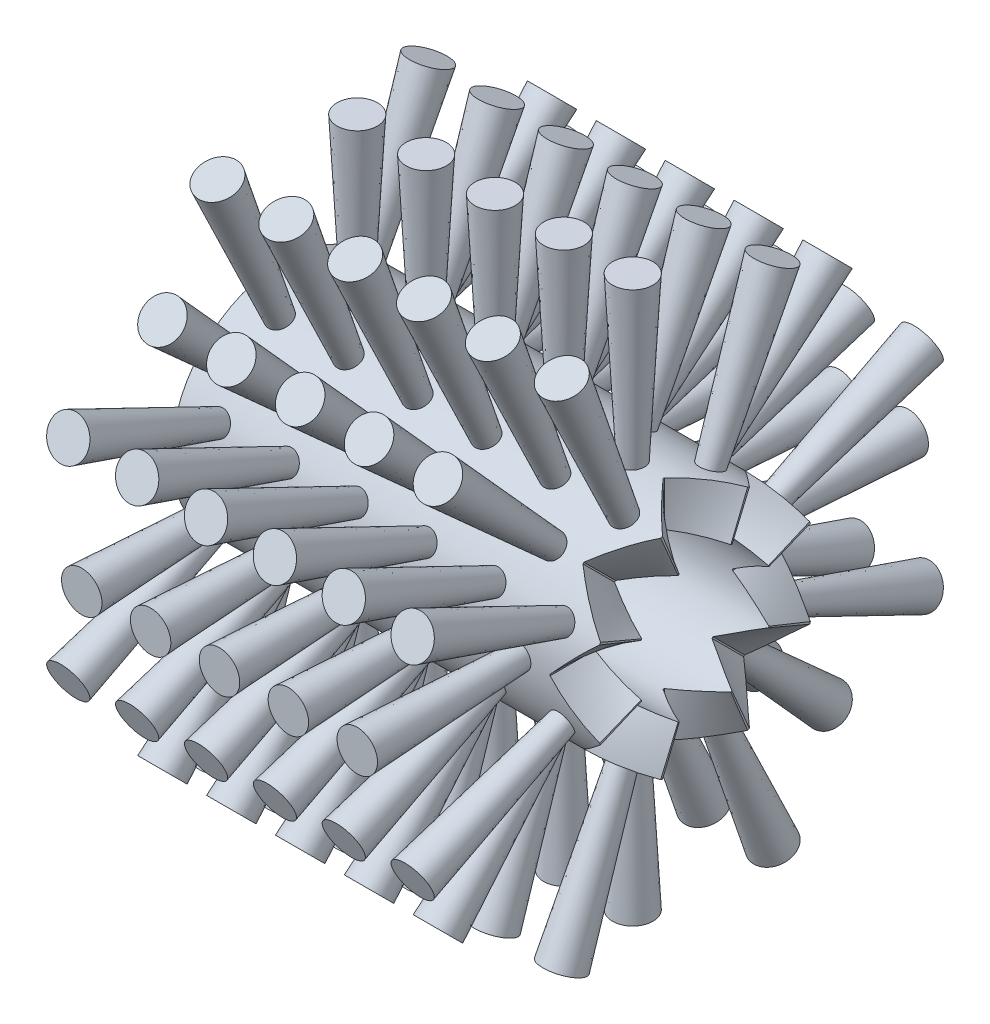
from build123d import *

# Parameters (mm, degrees)
SKIZZE1_R                         = 16.5
SKIZZE1_R_2                       = 10
LINEAR_AUSTRAGEN1_DEPTH           = 61
KREISMUSTER1_COUNT                = 8
SKIZZE8_R                         = 1.6
B_RSTE1_DEPTH                     = 25.5
B_RSTE1_TAPER                     = -3
SKIZZE9_R                         = 1.6
B_RTSE2_DEPTH                     = 25.5
B_RTSE2_TAPER                     = -3
KREISMUSTER3_COUNT                = 8
LINEARES_MUSTER1_COUNT            = 5
LINEARES_MUSTER1_PITCH            = 10
LINEARES_MUSTER1_COPY_1_SKETCH_R  = 1.6
LINEARES_MUSTER1_COPY_1_DEPTH     = 25.5
LINEARES_MUSTER1_COPY_1_TAPER     = -3
LINEARES_MUSTER1_COPY_2_SKETCH_R  = 1.6
LINEARES_MUSTER1_COPY_2_DEPTH     = 25.5
LINEARES_MUSTER1_COPY_2_TAPER     = -3
LINEARES_MUSTER1_COPY_3_SKETCH_R  = 1.6
LINEARES_MUSTER1_COPY_3_DEPTH     = 25.5
LINEARES_MUSTER1_COPY_3_TAPER     = -3
LINEARES_MUSTER1_COPY_4_SKETCH_R  = 1.6
LINEARES_MUSTER1_COPY_4_DEPTH     = 25.5
LINEARES_MUSTER1_COPY_4_TAPER     = -3
LINEARES_MUSTER1_COPY_5_SKETCH_R  = 1.6
LINEARES_MUSTER1_COPY_5_DEPTH     = 25.5
LINEARES_MUSTER1_COPY_5_TAPER     = -3
LINEARES_MUSTER1_COPY_6_SKETCH_R  = 1.6
LINEARES_MUSTER1_COPY_6_DEPTH     = 25.5
LINEARES_MUSTER1_COPY_6_TAPER     = -3
LINEARES_MUSTER1_COPY_7_SKETCH_R  = 1.6
LINEARES_MUSTER1_COPY_7_DEPTH     = 25.5
LINEARES_MUSTER1_COPY_7_TAPER     = -3
LINEARES_MUSTER1_COPY_8_SKETCH_R  = 1.6
LINEARES_MUSTER1_COPY_8_DEPTH     = 25.5
LINEARES_MUSTER1_COPY_8_TAPER     = -3
LINEARES_MUSTER1_COPY_9_SKETCH_R  = 1.6
LINEARES_MUSTER1_COPY_9_DEPTH     = 25.5
LINEARES_MUSTER1_COPY_9_TAPER     = -3
LINEARES_MUSTER1_COPY_10_SKETCH_R = 1.6
LINEARES_MUSTER1_COPY_10_DEPTH    = 25.5
LINEARES_MUSTER1_COPY_10_TAPER    = -3
LINEARES_MUSTER1_COPY_11_SKETCH_R = 1.6
LINEARES_MUSTER1_COPY_11_DEPTH    = 25.5
LINEARES_MUSTER1_COPY_11_TAPER    = -3
LINEARES_MUSTER1_COPY_12_SKETCH_R = 1.6
LINEARES_MUSTER1_COPY_12_DEPTH    = 25.5
LINEARES_MUSTER1_COPY_12_TAPER    = -3
LINEARES_MUSTER1_COPY_13_SKETCH_R = 1.6
LINEARES_MUSTER1_COPY_13_DEPTH    = 25.5
LINEARES_MUSTER1_COPY_13_TAPER    = -3
LINEARES_MUSTER1_COPY_14_SKETCH_R = 1.6
LINEARES_MUSTER1_COPY_14_DEPTH    = 25.5
LINEARES_MUSTER1_COPY_14_TAPER    = -3
LINEARES_MUSTER1_COPY_15_SKETCH_R = 1.6
LINEARES_MUSTER1_COPY_15_DEPTH    = 25.5
LINEARES_MUSTER1_COPY_15_TAPER    = -3
LINEARES_MUSTER1_COPY_16_SKETCH_R = 1.6
LINEARES_MUSTER1_COPY_16_DEPTH    = 25.5
LINEARES_MUSTER1_COPY_16_TAPER    = -3
LINEARES_MUSTER1_COPY_17_SKETCH_R = 1.6
LINEARES_MUSTER1_COPY_17_DEPTH    = 25.5
LINEARES_MUSTER1_COPY_17_TAPER    = -3
LINEARES_MUSTER1_COPY_18_SKETCH_R = 1.6
LINEARES_MUSTER1_COPY_18_DEPTH    = 25.5
LINEARES_MUSTER1_COPY_18_TAPER    = -3
LINEARES_MUSTER1_COPY_19_SKETCH_R = 1.6
LINEARES_MUSTER1_COPY_19_DEPTH    = 25.5
LINEARES_MUSTER1_COPY_19_TAPER    = -3
LINEARES_MUSTER1_COPY_20_SKETCH_R = 1.6
LINEARES_MUSTER1_COPY_20_DEPTH    = 25.5
LINEARES_MUSTER1_COPY_20_TAPER    = -3
LINEARES_MUSTER1_COPY_21_SKETCH_R = 1.6
LINEARES_MUSTER1_COPY_21_DEPTH    = 25.5
LINEARES_MUSTER1_COPY_21_TAPER    = -3
LINEARES_MUSTER1_COPY_22_SKETCH_R = 1.6
LINEARES_MUSTER1_COPY_22_DEPTH    = 25.5
LINEARES_MUSTER1_COPY_22_TAPER    = -3
LINEARES_MUSTER1_COPY_23_SKETCH_R = 1.6
LINEARES_MUSTER1_COPY_23_DEPTH    = 25.5
LINEARES_MUSTER1_COPY_23_TAPER    = -3
LINEARES_MUSTER1_COPY_24_SKETCH_R = 1.6
LINEARES_MUSTER1_COPY_24_DEPTH    = 25.5
LINEARES_MUSTER1_COPY_24_TAPER    = -3
LINEARES_MUSTER1_COPY_25_SKETCH_R = 1.6
LINEARES_MUSTER1_COPY_25_DEPTH    = 25.5
LINEARES_MUSTER1_COPY_25_TAPER    = -3
LINEARES_MUSTER1_COPY_26_SKETCH_R = 1.6
LINEARES_MUSTER1_COPY_26_DEPTH    = 25.5
LINEARES_MUSTER1_COPY_26_TAPER    = -3
LINEARES_MUSTER1_COPY_27_SKETCH_R = 1.6
LINEARES_MUSTER1_COPY_27_DEPTH    = 25.5
LINEARES_MUSTER1_COPY_27_TAPER    = -3
LINEARES_MUSTER1_COPY_28_SKETCH_R = 1.6
LINEARES_MUSTER1_COPY_28_DEPTH    = 25.5
LINEARES_MUSTER1_COPY_28_TAPER    = -3
KREISMUSTER4_COUNT                = 8
LINEARES_MUSTER2_COUNT            = 6
LINEARES_MUSTER2_PITCH            = 10
LINEARES_MUSTER2_COPY_1_SKETCH_R  = 1.6
LINEARES_MUSTER2_COPY_1_DEPTH     = 25.5
LINEARES_MUSTER2_COPY_1_TAPER     = -3
LINEARES_MUSTER2_COPY_2_SKETCH_R  = 1.6
LINEARES_MUSTER2_COPY_2_DEPTH     = 25.5
LINEARES_MUSTER2_COPY_2_TAPER     = -3
LINEARES_MUSTER2_COPY_3_SKETCH_R  = 1.6
LINEARES_MUSTER2_COPY_3_DEPTH     = 25.5
LINEARES_MUSTER2_COPY_3_TAPER     = -3
LINEARES_MUSTER2_COPY_4_SKETCH_R  = 1.6
LINEARES_MUSTER2_COPY_4_DEPTH     = 25.5
LINEARES_MUSTER2_COPY_4_TAPER     = -3
LINEARES_MUSTER2_COPY_5_SKETCH_R  = 1.6
LINEARES_MUSTER2_COPY_5_DEPTH     = 25.5
LINEARES_MUSTER2_COPY_5_TAPER     = -3
LINEARES_MUSTER2_COPY_6_SKETCH_R  = 1.6
LINEARES_MUSTER2_COPY_6_DEPTH     = 25.5
LINEARES_MUSTER2_COPY_6_TAPER     = -3
LINEARES_MUSTER2_COPY_7_SKETCH_R  = 1.6
LINEARES_MUSTER2_COPY_7_DEPTH     = 25.5
LINEARES_MUSTER2_COPY_7_TAPER     = -3
LINEARES_MUSTER2_COPY_8_SKETCH_R  = 1.6
LINEARES_MUSTER2_COPY_8_DEPTH     = 25.5
LINEARES_MUSTER2_COPY_8_TAPER     = -3
LINEARES_MUSTER2_COPY_9_SKETCH_R  = 1.6
LINEARES_MUSTER2_COPY_9_DEPTH     = 25.5
LINEARES_MUSTER2_COPY_9_TAPER     = -3
LINEARES_MUSTER2_COPY_10_SKETCH_R = 1.6
LINEARES_MUSTER2_COPY_10_DEPTH    = 25.5
LINEARES_MUSTER2_COPY_10_TAPER    = -3
LINEARES_MUSTER2_COPY_11_SKETCH_R = 1.6
LINEARES_MUSTER2_COPY_11_DEPTH    = 25.5
LINEARES_MUSTER2_COPY_11_TAPER    = -3
LINEARES_MUSTER2_COPY_12_SKETCH_R = 1.6
LINEARES_MUSTER2_COPY_12_DEPTH    = 25.5
LINEARES_MUSTER2_COPY_12_TAPER    = -3
LINEARES_MUSTER2_COPY_13_SKETCH_R = 1.6
LINEARES_MUSTER2_COPY_13_DEPTH    = 25.5
LINEARES_MUSTER2_COPY_13_TAPER    = -3
LINEARES_MUSTER2_COPY_14_SKETCH_R = 1.6
LINEARES_MUSTER2_COPY_14_DEPTH    = 25.5
LINEARES_MUSTER2_COPY_14_TAPER    = -3
LINEARES_MUSTER2_COPY_15_SKETCH_R = 1.6
LINEARES_MUSTER2_COPY_15_DEPTH    = 25.5
LINEARES_MUSTER2_COPY_15_TAPER    = -3
LINEARES_MUSTER2_COPY_16_SKETCH_R = 1.6
LINEARES_MUSTER2_COPY_16_DEPTH    = 25.5
LINEARES_MUSTER2_COPY_16_TAPER    = -3
LINEARES_MUSTER2_COPY_17_SKETCH_R = 1.6
LINEARES_MUSTER2_COPY_17_DEPTH    = 25.5
LINEARES_MUSTER2_COPY_17_TAPER    = -3
LINEARES_MUSTER2_COPY_18_SKETCH_R = 1.6
LINEARES_MUSTER2_COPY_18_DEPTH    = 25.5
LINEARES_MUSTER2_COPY_18_TAPER    = -3
LINEARES_MUSTER2_COPY_19_SKETCH_R = 1.6
LINEARES_MUSTER2_COPY_19_DEPTH    = 25.5
LINEARES_MUSTER2_COPY_19_TAPER    = -3
LINEARES_MUSTER2_COPY_20_SKETCH_R = 1.6
LINEARES_MUSTER2_COPY_20_DEPTH    = 25.5
LINEARES_MUSTER2_COPY_20_TAPER    = -3
LINEARES_MUSTER2_COPY_21_SKETCH_R = 1.6
LINEARES_MUSTER2_COPY_21_DEPTH    = 25.5
LINEARES_MUSTER2_COPY_21_TAPER    = -3
LINEARES_MUSTER2_COPY_22_SKETCH_R = 1.6
LINEARES_MUSTER2_COPY_22_DEPTH    = 25.5
LINEARES_MUSTER2_COPY_22_TAPER    = -3
LINEARES_MUSTER2_COPY_23_SKETCH_R = 1.6
LINEARES_MUSTER2_COPY_23_DEPTH    = 25.5
LINEARES_MUSTER2_COPY_23_TAPER    = -3
LINEARES_MUSTER2_COPY_24_SKETCH_R = 1.6
LINEARES_MUSTER2_COPY_24_DEPTH    = 25.5
LINEARES_MUSTER2_COPY_24_TAPER    = -3
LINEARES_MUSTER2_COPY_25_SKETCH_R = 1.6
LINEARES_MUSTER2_COPY_25_DEPTH    = 25.5
LINEARES_MUSTER2_COPY_25_TAPER    = -3
LINEARES_MUSTER2_COPY_26_SKETCH_R = 1.6
LINEARES_MUSTER2_COPY_26_DEPTH    = 25.5
LINEARES_MUSTER2_COPY_26_TAPER    = -3
LINEARES_MUSTER2_COPY_27_SKETCH_R = 1.6
LINEARES_MUSTER2_COPY_27_DEPTH    = 25.5
LINEARES_MUSTER2_COPY_27_TAPER    = -3
LINEARES_MUSTER2_COPY_28_SKETCH_R = 1.6
LINEARES_MUSTER2_COPY_28_DEPTH    = 25.5
LINEARES_MUSTER2_COPY_28_TAPER    = -3
LINEARES_MUSTER2_COPY_29_SKETCH_R = 1.6
LINEARES_MUSTER2_COPY_29_DEPTH    = 25.5
LINEARES_MUSTER2_COPY_29_TAPER    = -3
LINEARES_MUSTER2_COPY_30_SKETCH_R = 1.6
LINEARES_MUSTER2_COPY_30_DEPTH    = 25.5
LINEARES_MUSTER2_COPY_30_TAPER    = -3
LINEARES_MUSTER2_COPY_31_SKETCH_R = 1.6
LINEARES_MUSTER2_COPY_31_DEPTH    = 25.5
LINEARES_MUSTER2_COPY_31_TAPER    = -3
LINEARES_MUSTER2_COPY_32_SKETCH_R = 1.6
LINEARES_MUSTER2_COPY_32_DEPTH    = 25.5
LINEARES_MUSTER2_COPY_32_TAPER    = -3
LINEARES_MUSTER2_COPY_33_SKETCH_R = 1.6
LINEARES_MUSTER2_COPY_33_DEPTH    = 25.5
LINEARES_MUSTER2_COPY_33_TAPER    = -3
LINEARES_MUSTER2_COPY_34_SKETCH_R = 1.6
LINEARES_MUSTER2_COPY_34_DEPTH    = 25.5
LINEARES_MUSTER2_COPY_34_TAPER    = -3
LINEARES_MUSTER2_COPY_35_SKETCH_R = 1.6
LINEARES_MUSTER2_COPY_35_DEPTH    = 25.5
LINEARES_MUSTER2_COPY_35_TAPER    = -3


with BuildPart() as part:
    # Skizze1 → Linear austragen1 (new body)
    with BuildSketch(Plane(origin=(0, 0, 0), x_dir=(0, 0, -1), z_dir=(1, 0, 0))):
        Circle(SKIZZE1_R)
        Circle(SKIZZE1_R_2, mode=Mode.SUBTRACT)
    extrude(amount=LINEAR_AUSTRAGEN1_DEPTH)

    # Skizze5 → Schnitt-Ausformung1 section 0
    with BuildSketch(Plane(origin=(0, 8, 0), x_dir=(-1, 0, 0), z_dir=(0, 1, 0))):
        Polygon((-61, 3.232209807), (-55, 0.1), (-55, -0.1), (-61, -3.232209807), align=None)
    # Skizze4 → Schnitt-Ausformung1 section 1
    with BuildSketch(Plane(origin=(30.5, 16.5, 0), x_dir=(0, 0, -1), z_dir=(0, 1, 0))):
        Polygon((6.666432726, -30.5), (0.1, -24.5), (-0.1, -24.5), (-6.666432726, -30.5), align=None)
    schnitt_ausformung1 = loft(mode=Mode.SUBTRACT)

    # Kreismuster1: Schnitt-Ausformung1 ×8 about axis
    kreismuster1_axis = Axis((61, 0, 0), (-1, 0, 0))
    for i in range(1, KREISMUSTER1_COUNT):
        add(schnitt_ausformung1.rotate(kreismuster1_axis, i * 360 / KREISMUSTER1_COUNT), mode=Mode.SUBTRACT)

    # Skizze8 → Bürste1 (add)
    with BuildSketch(Plane(origin=(0, 14.5, 0), x_dir=(-1, 0, 0), z_dir=(0, 1, 0))):
        with Locations((-50.5, 0)):
            Circle(SKIZZE8_R)
    b_rste1 = extrude(amount=B_RSTE1_DEPTH, taper=B_RSTE1_TAPER)

    # Skizze9 → Bürtse2 (add)
    with BuildSketch(Plane(origin=(0, 13.396253221, 5.548909769), x_dir=(-1, 0, 0), z_dir=(0, 0.923879533, 0.382683432))):
        with Locations((-55.5, 0)):
            Circle(SKIZZE9_R)
    b_rtse2 = extrude(amount=B_RTSE2_DEPTH, taper=B_RTSE2_TAPER)

    # Kreismuster3: Bürste1 ×8 about axis
    kreismuster3_axis = Axis((0, 0, 0), (1, 0, 0))
    for i in range(1, KREISMUSTER3_COUNT):
        add(b_rste1.rotate(kreismuster3_axis, i * 360 / KREISMUSTER3_COUNT))

    # Lineares Muster1: Bürste1 ×5
    with Locations(*[(-i * LINEARES_MUSTER1_PITCH, 0, 0) for i in range(1, LINEARES_MUSTER1_COUNT)]):
        add(b_rste1)

    # Lineares Muster1 copy 1 sketch → Lineares Muster1 copy 1 (add)
    with BuildSketch(Plane(origin=(-10, 10.253048327, 10.253048327), x_dir=(-1, 0, 0), z_dir=(0, 0.707106781, 0.707106781))):
        with Locations((-50.5, 0)):
            Circle(LINEARES_MUSTER1_COPY_1_SKETCH_R)
    extrude(amount=LINEARES_MUSTER1_COPY_1_DEPTH, taper=LINEARES_MUSTER1_COPY_1_TAPER)

    # Lineares Muster1 copy 2 sketch → Lineares Muster1 copy 2 (add)
    with BuildSketch(Plane(origin=(-20, 10.253048327, 10.253048327), x_dir=(-1, 0, 0), z_dir=(0, 0.707106781, 0.707106781))):
        with Locations((-50.5, 0)):
            Circle(LINEARES_MUSTER1_COPY_2_SKETCH_R)
    extrude(amount=LINEARES_MUSTER1_COPY_2_DEPTH, taper=LINEARES_MUSTER1_COPY_2_TAPER)

    # Lineares Muster1 copy 3 sketch → Lineares Muster1 copy 3 (add)
    with BuildSketch(Plane(origin=(-30, 10.253048327, 10.253048327), x_dir=(-1, 0, 0), z_dir=(0, 0.707106781, 0.707106781))):
        with Locations((-50.5, 0)):
            Circle(LINEARES_MUSTER1_COPY_3_SKETCH_R)
    extrude(amount=LINEARES_MUSTER1_COPY_3_DEPTH, taper=LINEARES_MUSTER1_COPY_3_TAPER)

    # Lineares Muster1 copy 4 sketch → Lineares Muster1 copy 4 (add)
    with BuildSketch(Plane(origin=(-40, 10.253048327, 10.253048327), x_dir=(-1, 0, 0), z_dir=(0, 0.707106781, 0.707106781))):
        with Locations((-50.5, 0)):
            Circle(LINEARES_MUSTER1_COPY_4_SKETCH_R)
    extrude(amount=LINEARES_MUSTER1_COPY_4_DEPTH, taper=LINEARES_MUSTER1_COPY_4_TAPER)

    # Lineares Muster1 copy 5 sketch → Lineares Muster1 copy 5 (add)
    with BuildSketch(Plane(origin=(-10, 0, 14.5), x_dir=(-1, 0, 0), z_dir=(0, 0, 1))):
        with Locations((-50.5, 0)):
            Circle(LINEARES_MUSTER1_COPY_5_SKETCH_R)
    extrude(amount=LINEARES_MUSTER1_COPY_5_DEPTH, taper=LINEARES_MUSTER1_COPY_5_TAPER)

    # Lineares Muster1 copy 6 sketch → Lineares Muster1 copy 6 (add)
    with BuildSketch(Plane(origin=(-20, 0, 14.5), x_dir=(-1, 0, 0), z_dir=(0, 0, 1))):
        with Locations((-50.5, 0)):
            Circle(LINEARES_MUSTER1_COPY_6_SKETCH_R)
    extrude(amount=LINEARES_MUSTER1_COPY_6_DEPTH, taper=LINEARES_MUSTER1_COPY_6_TAPER)

    # Lineares Muster1 copy 7 sketch → Lineares Muster1 copy 7 (add)
    with BuildSketch(Plane(origin=(-30, 0, 14.5), x_dir=(-1, 0, 0), z_dir=(0, 0, 1))):
        with Locations((-50.5, 0)):
            Circle(LINEARES_MUSTER1_COPY_7_SKETCH_R)
    extrude(amount=LINEARES_MUSTER1_COPY_7_DEPTH, taper=LINEARES_MUSTER1_COPY_7_TAPER)

    # Lineares Muster1 copy 8 sketch → Lineares Muster1 copy 8 (add)
    with BuildSketch(Plane(origin=(-40, 0, 14.5), x_dir=(-1, 0, 0), z_dir=(0, 0, 1))):
        with Locations((-50.5, 0)):
            Circle(LINEARES_MUSTER1_COPY_8_SKETCH_R)
    extrude(amount=LINEARES_MUSTER1_COPY_8_DEPTH, taper=LINEARES_MUSTER1_COPY_8_TAPER)

    # Lineares Muster1 copy 9 sketch → Lineares Muster1 copy 9 (add)
    with BuildSketch(Plane(origin=(-10, -10.253048327, 10.253048327), x_dir=(-1, 0, 0), z_dir=(0, -0.707106781, 0.707106781))):
        with Locations((-50.5, 0)):
            Circle(LINEARES_MUSTER1_COPY_9_SKETCH_R)
    extrude(amount=LINEARES_MUSTER1_COPY_9_DEPTH, taper=LINEARES_MUSTER1_COPY_9_TAPER)

    # Lineares Muster1 copy 10 sketch → Lineares Muster1 copy 10 (add)
    with BuildSketch(Plane(origin=(-20, -10.253048327, 10.253048327), x_dir=(-1, 0, 0), z_dir=(0, -0.707106781, 0.707106781))):
        with Locations((-50.5, 0)):
            Circle(LINEARES_MUSTER1_COPY_10_SKETCH_R)
    extrude(amount=LINEARES_MUSTER1_COPY_10_DEPTH, taper=LINEARES_MUSTER1_COPY_10_TAPER)

    # Lineares Muster1 copy 11 sketch → Lineares Muster1 copy 11 (add)
    with BuildSketch(Plane(origin=(-30, -10.253048327, 10.253048327), x_dir=(-1, 0, 0), z_dir=(0, -0.707106781, 0.707106781))):
        with Locations((-50.5, 0)):
            Circle(LINEARES_MUSTER1_COPY_11_SKETCH_R)
    extrude(amount=LINEARES_MUSTER1_COPY_11_DEPTH, taper=LINEARES_MUSTER1_COPY_11_TAPER)

    # Lineares Muster1 copy 12 sketch → Lineares Muster1 copy 12 (add)
    with BuildSketch(Plane(origin=(-40, -10.253048327, 10.253048327), x_dir=(-1, 0, 0), z_dir=(0, -0.707106781, 0.707106781))):
        with Locations((-50.5, 0)):
            Circle(LINEARES_MUSTER1_COPY_12_SKETCH_R)
    extrude(amount=LINEARES_MUSTER1_COPY_12_DEPTH, taper=LINEARES_MUSTER1_COPY_12_TAPER)

    # Lineares Muster1 copy 13 sketch → Lineares Muster1 copy 13 (add)
    with BuildSketch(Plane(origin=(-10, -14.5, 0), x_dir=(-1, 0, 0), z_dir=(0, -1, 0))):
        with Locations((-50.5, 0)):
            Circle(LINEARES_MUSTER1_COPY_13_SKETCH_R)
    extrude(amount=LINEARES_MUSTER1_COPY_13_DEPTH, taper=LINEARES_MUSTER1_COPY_13_TAPER)

    # Lineares Muster1 copy 14 sketch → Lineares Muster1 copy 14 (add)
    with BuildSketch(Plane(origin=(-20, -14.5, 0), x_dir=(-1, 0, 0), z_dir=(0, -1, 0))):
        with Locations((-50.5, 0)):
            Circle(LINEARES_MUSTER1_COPY_14_SKETCH_R)
    extrude(amount=LINEARES_MUSTER1_COPY_14_DEPTH, taper=LINEARES_MUSTER1_COPY_14_TAPER)

    # Lineares Muster1 copy 15 sketch → Lineares Muster1 copy 15 (add)
    with BuildSketch(Plane(origin=(-30, -14.5, 0), x_dir=(-1, 0, 0), z_dir=(0, -1, 0))):
        with Locations((-50.5, 0)):
            Circle(LINEARES_MUSTER1_COPY_15_SKETCH_R)
    extrude(amount=LINEARES_MUSTER1_COPY_15_DEPTH, taper=LINEARES_MUSTER1_COPY_15_TAPER)

    # Lineares Muster1 copy 16 sketch → Lineares Muster1 copy 16 (add)
    with BuildSketch(Plane(origin=(-40, -14.5, 0), x_dir=(-1, 0, 0), z_dir=(0, -1, 0))):
        with Locations((-50.5, 0)):
            Circle(LINEARES_MUSTER1_COPY_16_SKETCH_R)
    extrude(amount=LINEARES_MUSTER1_COPY_16_DEPTH, taper=LINEARES_MUSTER1_COPY_16_TAPER)

    # Lineares Muster1 copy 17 sketch → Lineares Muster1 copy 17 (add)
    with BuildSketch(Plane(origin=(-10, -10.253048327, -10.253048327), x_dir=(-1, 0, 0), z_dir=(0, -0.707106781, -0.707106781))):
        with Locations((-50.5, 0)):
            Circle(LINEARES_MUSTER1_COPY_17_SKETCH_R)
    extrude(amount=LINEARES_MUSTER1_COPY_17_DEPTH, taper=LINEARES_MUSTER1_COPY_17_TAPER)

    # Lineares Muster1 copy 18 sketch → Lineares Muster1 copy 18 (add)
    with BuildSketch(Plane(origin=(-20, -10.253048327, -10.253048327), x_dir=(-1, 0, 0), z_dir=(0, -0.707106781, -0.707106781))):
        with Locations((-50.5, 0)):
            Circle(LINEARES_MUSTER1_COPY_18_SKETCH_R)
    extrude(amount=LINEARES_MUSTER1_COPY_18_DEPTH, taper=LINEARES_MUSTER1_COPY_18_TAPER)

    # Lineares Muster1 copy 19 sketch → Lineares Muster1 copy 19 (add)
    with BuildSketch(Plane(origin=(-30, -10.253048327, -10.253048327), x_dir=(-1, 0, 0), z_dir=(0, -0.707106781, -0.707106781))):
        with Locations((-50.5, 0)):
            Circle(LINEARES_MUSTER1_COPY_19_SKETCH_R)
    extrude(amount=LINEARES_MUSTER1_COPY_19_DEPTH, taper=LINEARES_MUSTER1_COPY_19_TAPER)

    # Lineares Muster1 copy 20 sketch → Lineares Muster1 copy 20 (add)
    with BuildSketch(Plane(origin=(-40, -10.253048327, -10.253048327), x_dir=(-1, 0, 0), z_dir=(0, -0.707106781, -0.707106781))):
        with Locations((-50.5, 0)):
            Circle(LINEARES_MUSTER1_COPY_20_SKETCH_R)
    extrude(amount=LINEARES_MUSTER1_COPY_20_DEPTH, taper=LINEARES_MUSTER1_COPY_20_TAPER)

    # Lineares Muster1 copy 21 sketch → Lineares Muster1 copy 21 (add)
    with BuildSketch(Plane(origin=(-10, 0, -14.5), x_dir=(-1, 0, 0), z_dir=(0, 0, -1))):
        with Locations((-50.5, 0)):
            Circle(LINEARES_MUSTER1_COPY_21_SKETCH_R)
    extrude(amount=LINEARES_MUSTER1_COPY_21_DEPTH, taper=LINEARES_MUSTER1_COPY_21_TAPER)

    # Lineares Muster1 copy 22 sketch → Lineares Muster1 copy 22 (add)
    with BuildSketch(Plane(origin=(-20, 0, -14.5), x_dir=(-1, 0, 0), z_dir=(0, 0, -1))):
        with Locations((-50.5, 0)):
            Circle(LINEARES_MUSTER1_COPY_22_SKETCH_R)
    extrude(amount=LINEARES_MUSTER1_COPY_22_DEPTH, taper=LINEARES_MUSTER1_COPY_22_TAPER)

    # Lineares Muster1 copy 23 sketch → Lineares Muster1 copy 23 (add)
    with BuildSketch(Plane(origin=(-30, 0, -14.5), x_dir=(-1, 0, 0), z_dir=(0, 0, -1))):
        with Locations((-50.5, 0)):
            Circle(LINEARES_MUSTER1_COPY_23_SKETCH_R)
    extrude(amount=LINEARES_MUSTER1_COPY_23_DEPTH, taper=LINEARES_MUSTER1_COPY_23_TAPER)

    # Lineares Muster1 copy 24 sketch → Lineares Muster1 copy 24 (add)
    with BuildSketch(Plane(origin=(-40, 0, -14.5), x_dir=(-1, 0, 0), z_dir=(0, 0, -1))):
        with Locations((-50.5, 0)):
            Circle(LINEARES_MUSTER1_COPY_24_SKETCH_R)
    extrude(amount=LINEARES_MUSTER1_COPY_24_DEPTH, taper=LINEARES_MUSTER1_COPY_24_TAPER)

    # Lineares Muster1 copy 25 sketch → Lineares Muster1 copy 25 (add)
    with BuildSketch(Plane(origin=(-10, 10.253048327, -10.253048327), x_dir=(-1, 0, 0), z_dir=(0, 0.707106781, -0.707106781))):
        with Locations((-50.5, 0)):
            Circle(LINEARES_MUSTER1_COPY_25_SKETCH_R)
    extrude(amount=LINEARES_MUSTER1_COPY_25_DEPTH, taper=LINEARES_MUSTER1_COPY_25_TAPER)

    # Lineares Muster1 copy 26 sketch → Lineares Muster1 copy 26 (add)
    with BuildSketch(Plane(origin=(-20, 10.253048327, -10.253048327), x_dir=(-1, 0, 0), z_dir=(0, 0.707106781, -0.707106781))):
        with Locations((-50.5, 0)):
            Circle(LINEARES_MUSTER1_COPY_26_SKETCH_R)
    extrude(amount=LINEARES_MUSTER1_COPY_26_DEPTH, taper=LINEARES_MUSTER1_COPY_26_TAPER)

    # Lineares Muster1 copy 27 sketch → Lineares Muster1 copy 27 (add)
    with BuildSketch(Plane(origin=(-30, 10.253048327, -10.253048327), x_dir=(-1, 0, 0), z_dir=(0, 0.707106781, -0.707106781))):
        with Locations((-50.5, 0)):
            Circle(LINEARES_MUSTER1_COPY_27_SKETCH_R)
    extrude(amount=LINEARES_MUSTER1_COPY_27_DEPTH, taper=LINEARES_MUSTER1_COPY_27_TAPER)

    # Lineares Muster1 copy 28 sketch → Lineares Muster1 copy 28 (add)
    with BuildSketch(Plane(origin=(-40, 10.253048327, -10.253048327), x_dir=(-1, 0, 0), z_dir=(0, 0.707106781, -0.707106781))):
        with Locations((-50.5, 0)):
            Circle(LINEARES_MUSTER1_COPY_28_SKETCH_R)
    extrude(amount=LINEARES_MUSTER1_COPY_28_DEPTH, taper=LINEARES_MUSTER1_COPY_28_TAPER)

    # Kreismuster4: Bürtse2 ×8 about axis
    kreismuster4_axis = Axis((0, 0, 0), (1, 0, 0))
    for i in range(1, KREISMUSTER4_COUNT):
        add(b_rtse2.rotate(kreismuster4_axis, i * 360 / KREISMUSTER4_COUNT))

    # Lineares Muster2: Bürtse2 ×6
    with Locations(*[(-i * LINEARES_MUSTER2_PITCH, 0, 0) for i in range(1, LINEARES_MUSTER2_COUNT)]):
        add(b_rtse2)

    # Lineares Muster2 copy 1 sketch → Lineares Muster2 copy 1 (add)
    with BuildSketch(Plane(origin=(-10, 5.548909769, 13.396253221), x_dir=(-1, 0, 0), z_dir=(0, 0.382683432, 0.923879533))):
        with Locations((-55.5, 0)):
            Circle(LINEARES_MUSTER2_COPY_1_SKETCH_R)
    extrude(amount=LINEARES_MUSTER2_COPY_1_DEPTH, taper=LINEARES_MUSTER2_COPY_1_TAPER)

    # Lineares Muster2 copy 2 sketch → Lineares Muster2 copy 2 (add)
    with BuildSketch(Plane(origin=(-20, 5.548909769, 13.396253221), x_dir=(-1, 0, 0), z_dir=(0, 0.382683432, 0.923879533))):
        with Locations((-55.5, 0)):
            Circle(LINEARES_MUSTER2_COPY_2_SKETCH_R)
    extrude(amount=LINEARES_MUSTER2_COPY_2_DEPTH, taper=LINEARES_MUSTER2_COPY_2_TAPER)

    # Lineares Muster2 copy 3 sketch → Lineares Muster2 copy 3 (add)
    with BuildSketch(Plane(origin=(-30, 5.548909769, 13.396253221), x_dir=(-1, 0, 0), z_dir=(0, 0.382683432, 0.923879533))):
        with Locations((-55.5, 0)):
            Circle(LINEARES_MUSTER2_COPY_3_SKETCH_R)
    extrude(amount=LINEARES_MUSTER2_COPY_3_DEPTH, taper=LINEARES_MUSTER2_COPY_3_TAPER)

    # Lineares Muster2 copy 4 sketch → Lineares Muster2 copy 4 (add)
    with BuildSketch(Plane(origin=(-40, 5.548909769, 13.396253221), x_dir=(-1, 0, 0), z_dir=(0, 0.382683432, 0.923879533))):
        with Locations((-55.5, 0)):
            Circle(LINEARES_MUSTER2_COPY_4_SKETCH_R)
    extrude(amount=LINEARES_MUSTER2_COPY_4_DEPTH, taper=LINEARES_MUSTER2_COPY_4_TAPER)

    # Lineares Muster2 copy 5 sketch → Lineares Muster2 copy 5 (add)
    with BuildSketch(Plane(origin=(-50, 5.548909769, 13.396253221), x_dir=(-1, 0, 0), z_dir=(0, 0.382683432, 0.923879533))):
        with Locations((-55.5, 0)):
            Circle(LINEARES_MUSTER2_COPY_5_SKETCH_R)
    extrude(amount=LINEARES_MUSTER2_COPY_5_DEPTH, taper=LINEARES_MUSTER2_COPY_5_TAPER)

    # Lineares Muster2 copy 6 sketch → Lineares Muster2 copy 6 (add)
    with BuildSketch(Plane(origin=(-10, -5.548909769, 13.396253221), x_dir=(-1, 0, 0), z_dir=(0, -0.382683432, 0.923879533))):
        with Locations((-55.5, 0)):
            Circle(LINEARES_MUSTER2_COPY_6_SKETCH_R)
    extrude(amount=LINEARES_MUSTER2_COPY_6_DEPTH, taper=LINEARES_MUSTER2_COPY_6_TAPER)

    # Lineares Muster2 copy 7 sketch → Lineares Muster2 copy 7 (add)
    with BuildSketch(Plane(origin=(-20, -5.548909769, 13.396253221), x_dir=(-1, 0, 0), z_dir=(0, -0.382683432, 0.923879533))):
        with Locations((-55.5, 0)):
            Circle(LINEARES_MUSTER2_COPY_7_SKETCH_R)
    extrude(amount=LINEARES_MUSTER2_COPY_7_DEPTH, taper=LINEARES_MUSTER2_COPY_7_TAPER)

    # Lineares Muster2 copy 8 sketch → Lineares Muster2 copy 8 (add)
    with BuildSketch(Plane(origin=(-30, -5.548909769, 13.396253221), x_dir=(-1, 0, 0), z_dir=(0, -0.382683432, 0.923879533))):
        with Locations((-55.5, 0)):
            Circle(LINEARES_MUSTER2_COPY_8_SKETCH_R)
    extrude(amount=LINEARES_MUSTER2_COPY_8_DEPTH, taper=LINEARES_MUSTER2_COPY_8_TAPER)

    # Lineares Muster2 copy 9 sketch → Lineares Muster2 copy 9 (add)
    with BuildSketch(Plane(origin=(-40, -5.548909769, 13.396253221), x_dir=(-1, 0, 0), z_dir=(0, -0.382683432, 0.923879533))):
        with Locations((-55.5, 0)):
            Circle(LINEARES_MUSTER2_COPY_9_SKETCH_R)
    extrude(amount=LINEARES_MUSTER2_COPY_9_DEPTH, taper=LINEARES_MUSTER2_COPY_9_TAPER)

    # Lineares Muster2 copy 10 sketch → Lineares Muster2 copy 10 (add)
    with BuildSketch(Plane(origin=(-50, -5.548909769, 13.396253221), x_dir=(-1, 0, 0), z_dir=(0, -0.382683432, 0.923879533))):
        with Locations((-55.5, 0)):
            Circle(LINEARES_MUSTER2_COPY_10_SKETCH_R)
    extrude(amount=LINEARES_MUSTER2_COPY_10_DEPTH, taper=LINEARES_MUSTER2_COPY_10_TAPER)

    # Lineares Muster2 copy 11 sketch → Lineares Muster2 copy 11 (add)
    with BuildSketch(Plane(origin=(-10, -13.396253221, 5.548909769), x_dir=(-1, 0, 0), z_dir=(0, -0.923879533, 0.382683432))):
        with Locations((-55.5, 0)):
            Circle(LINEARES_MUSTER2_COPY_11_SKETCH_R)
    extrude(amount=LINEARES_MUSTER2_COPY_11_DEPTH, taper=LINEARES_MUSTER2_COPY_11_TAPER)

    # Lineares Muster2 copy 12 sketch → Lineares Muster2 copy 12 (add)
    with BuildSketch(Plane(origin=(-20, -13.396253221, 5.548909769), x_dir=(-1, 0, 0), z_dir=(0, -0.923879533, 0.382683432))):
        with Locations((-55.5, 0)):
            Circle(LINEARES_MUSTER2_COPY_12_SKETCH_R)
    extrude(amount=LINEARES_MUSTER2_COPY_12_DEPTH, taper=LINEARES_MUSTER2_COPY_12_TAPER)

    # Lineares Muster2 copy 13 sketch → Lineares Muster2 copy 13 (add)
    with BuildSketch(Plane(origin=(-30, -13.396253221, 5.548909769), x_dir=(-1, 0, 0), z_dir=(0, -0.923879533, 0.382683432))):
        with Locations((-55.5, 0)):
            Circle(LINEARES_MUSTER2_COPY_13_SKETCH_R)
    extrude(amount=LINEARES_MUSTER2_COPY_13_DEPTH, taper=LINEARES_MUSTER2_COPY_13_TAPER)

    # Lineares Muster2 copy 14 sketch → Lineares Muster2 copy 14 (add)
    with BuildSketch(Plane(origin=(-40, -13.396253221, 5.548909769), x_dir=(-1, 0, 0), z_dir=(0, -0.923879533, 0.382683432))):
        with Locations((-55.5, 0)):
            Circle(LINEARES_MUSTER2_COPY_14_SKETCH_R)
    extrude(amount=LINEARES_MUSTER2_COPY_14_DEPTH, taper=LINEARES_MUSTER2_COPY_14_TAPER)

    # Lineares Muster2 copy 15 sketch → Lineares Muster2 copy 15 (add)
    with BuildSketch(Plane(origin=(-50, -13.396253221, 5.548909769), x_dir=(-1, 0, 0), z_dir=(0, -0.923879533, 0.382683432))):
        with Locations((-55.5, 0)):
            Circle(LINEARES_MUSTER2_COPY_15_SKETCH_R)
    extrude(amount=LINEARES_MUSTER2_COPY_15_DEPTH, taper=LINEARES_MUSTER2_COPY_15_TAPER)

    # Lineares Muster2 copy 16 sketch → Lineares Muster2 copy 16 (add)
    with BuildSketch(Plane(origin=(-10, -13.396253221, -5.548909769), x_dir=(-1, 0, 0), z_dir=(0, -0.923879533, -0.382683432))):
        with Locations((-55.5, 0)):
            Circle(LINEARES_MUSTER2_COPY_16_SKETCH_R)
    extrude(amount=LINEARES_MUSTER2_COPY_16_DEPTH, taper=LINEARES_MUSTER2_COPY_16_TAPER)

    # Lineares Muster2 copy 17 sketch → Lineares Muster2 copy 17 (add)
    with BuildSketch(Plane(origin=(-20, -13.396253221, -5.548909769), x_dir=(-1, 0, 0), z_dir=(0, -0.923879533, -0.382683432))):
        with Locations((-55.5, 0)):
            Circle(LINEARES_MUSTER2_COPY_17_SKETCH_R)
    extrude(amount=LINEARES_MUSTER2_COPY_17_DEPTH, taper=LINEARES_MUSTER2_COPY_17_TAPER)

    # Lineares Muster2 copy 18 sketch → Lineares Muster2 copy 18 (add)
    with BuildSketch(Plane(origin=(-30, -13.396253221, -5.548909769), x_dir=(-1, 0, 0), z_dir=(0, -0.923879533, -0.382683432))):
        with Locations((-55.5, 0)):
            Circle(LINEARES_MUSTER2_COPY_18_SKETCH_R)
    extrude(amount=LINEARES_MUSTER2_COPY_18_DEPTH, taper=LINEARES_MUSTER2_COPY_18_TAPER)

    # Lineares Muster2 copy 19 sketch → Lineares Muster2 copy 19 (add)
    with BuildSketch(Plane(origin=(-40, -13.396253221, -5.548909769), x_dir=(-1, 0, 0), z_dir=(0, -0.923879533, -0.382683432))):
        with Locations((-55.5, 0)):
            Circle(LINEARES_MUSTER2_COPY_19_SKETCH_R)
    extrude(amount=LINEARES_MUSTER2_COPY_19_DEPTH, taper=LINEARES_MUSTER2_COPY_19_TAPER)

    # Lineares Muster2 copy 20 sketch → Lineares Muster2 copy 20 (add)
    with BuildSketch(Plane(origin=(-50, -13.396253221, -5.548909769), x_dir=(-1, 0, 0), z_dir=(0, -0.923879533, -0.382683432))):
        with Locations((-55.5, 0)):
            Circle(LINEARES_MUSTER2_COPY_20_SKETCH_R)
    extrude(amount=LINEARES_MUSTER2_COPY_20_DEPTH, taper=LINEARES_MUSTER2_COPY_20_TAPER)

    # Lineares Muster2 copy 21 sketch → Lineares Muster2 copy 21 (add)
    with BuildSketch(Plane(origin=(-10, -5.548909769, -13.396253221), x_dir=(-1, 0, 0), z_dir=(0, -0.382683432, -0.923879533))):
        with Locations((-55.5, 0)):
            Circle(LINEARES_MUSTER2_COPY_21_SKETCH_R)
    extrude(amount=LINEARES_MUSTER2_COPY_21_DEPTH, taper=LINEARES_MUSTER2_COPY_21_TAPER)

    # Lineares Muster2 copy 22 sketch → Lineares Muster2 copy 22 (add)
    with BuildSketch(Plane(origin=(-20, -5.548909769, -13.396253221), x_dir=(-1, 0, 0), z_dir=(0, -0.382683432, -0.923879533))):
        with Locations((-55.5, 0)):
            Circle(LINEARES_MUSTER2_COPY_22_SKETCH_R)
    extrude(amount=LINEARES_MUSTER2_COPY_22_DEPTH, taper=LINEARES_MUSTER2_COPY_22_TAPER)

    # Lineares Muster2 copy 23 sketch → Lineares Muster2 copy 23 (add)
    with BuildSketch(Plane(origin=(-30, -5.548909769, -13.396253221), x_dir=(-1, 0, 0), z_dir=(0, -0.382683432, -0.923879533))):
        with Locations((-55.5, 0)):
            Circle(LINEARES_MUSTER2_COPY_23_SKETCH_R)
    extrude(amount=LINEARES_MUSTER2_COPY_23_DEPTH, taper=LINEARES_MUSTER2_COPY_23_TAPER)

    # Lineares Muster2 copy 24 sketch → Lineares Muster2 copy 24 (add)
    with BuildSketch(Plane(origin=(-40, -5.548909769, -13.396253221), x_dir=(-1, 0, 0), z_dir=(0, -0.382683432, -0.923879533))):
        with Locations((-55.5, 0)):
            Circle(LINEARES_MUSTER2_COPY_24_SKETCH_R)
    extrude(amount=LINEARES_MUSTER2_COPY_24_DEPTH, taper=LINEARES_MUSTER2_COPY_24_TAPER)

    # Lineares Muster2 copy 25 sketch → Lineares Muster2 copy 25 (add)
    with BuildSketch(Plane(origin=(-50, -5.548909769, -13.396253221), x_dir=(-1, 0, 0), z_dir=(0, -0.382683432, -0.923879533))):
        with Locations((-55.5, 0)):
            Circle(LINEARES_MUSTER2_COPY_25_SKETCH_R)
    extrude(amount=LINEARES_MUSTER2_COPY_25_DEPTH, taper=LINEARES_MUSTER2_COPY_25_TAPER)

    # Lineares Muster2 copy 26 sketch → Lineares Muster2 copy 26 (add)
    with BuildSketch(Plane(origin=(-10, 5.548909769, -13.396253221), x_dir=(-1, 0, 0), z_dir=(0, 0.382683432, -0.923879533))):
        with Locations((-55.5, 0)):
            Circle(LINEARES_MUSTER2_COPY_26_SKETCH_R)
    extrude(amount=LINEARES_MUSTER2_COPY_26_DEPTH, taper=LINEARES_MUSTER2_COPY_26_TAPER)

    # Lineares Muster2 copy 27 sketch → Lineares Muster2 copy 27 (add)
    with BuildSketch(Plane(origin=(-20, 5.548909769, -13.396253221), x_dir=(-1, 0, 0), z_dir=(0, 0.382683432, -0.923879533))):
        with Locations((-55.5, 0)):
            Circle(LINEARES_MUSTER2_COPY_27_SKETCH_R)
    extrude(amount=LINEARES_MUSTER2_COPY_27_DEPTH, taper=LINEARES_MUSTER2_COPY_27_TAPER)

    # Lineares Muster2 copy 28 sketch → Lineares Muster2 copy 28 (add)
    with BuildSketch(Plane(origin=(-30, 5.548909769, -13.396253221), x_dir=(-1, 0, 0), z_dir=(0, 0.382683432, -0.923879533))):
        with Locations((-55.5, 0)):
            Circle(LINEARES_MUSTER2_COPY_28_SKETCH_R)
    extrude(amount=LINEARES_MUSTER2_COPY_28_DEPTH, taper=LINEARES_MUSTER2_COPY_28_TAPER)

    # Lineares Muster2 copy 29 sketch → Lineares Muster2 copy 29 (add)
    with BuildSketch(Plane(origin=(-40, 5.548909769, -13.396253221), x_dir=(-1, 0, 0), z_dir=(0, 0.382683432, -0.923879533))):
        with Locations((-55.5, 0)):
            Circle(LINEARES_MUSTER2_COPY_29_SKETCH_R)
    extrude(amount=LINEARES_MUSTER2_COPY_29_DEPTH, taper=LINEARES_MUSTER2_COPY_29_TAPER)

    # Lineares Muster2 copy 30 sketch → Lineares Muster2 copy 30 (add)
    with BuildSketch(Plane(origin=(-50, 5.548909769, -13.396253221), x_dir=(-1, 0, 0), z_dir=(0, 0.382683432, -0.923879533))):
        with Locations((-55.5, 0)):
            Circle(LINEARES_MUSTER2_COPY_30_SKETCH_R)
    extrude(amount=LINEARES_MUSTER2_COPY_30_DEPTH, taper=LINEARES_MUSTER2_COPY_30_TAPER)

    # Lineares Muster2 copy 31 sketch → Lineares Muster2 copy 31 (add)
    with BuildSketch(Plane(origin=(-10, 13.396253221, -5.548909769), x_dir=(-1, 0, 0), z_dir=(0, 0.923879533, -0.382683432))):
        with Locations((-55.5, 0)):
            Circle(LINEARES_MUSTER2_COPY_31_SKETCH_R)
    extrude(amount=LINEARES_MUSTER2_COPY_31_DEPTH, taper=LINEARES_MUSTER2_COPY_31_TAPER)

    # Lineares Muster2 copy 32 sketch → Lineares Muster2 copy 32 (add)
    with BuildSketch(Plane(origin=(-20, 13.396253221, -5.548909769), x_dir=(-1, 0, 0), z_dir=(0, 0.923879533, -0.382683432))):
        with Locations((-55.5, 0)):
            Circle(LINEARES_MUSTER2_COPY_32_SKETCH_R)
    extrude(amount=LINEARES_MUSTER2_COPY_32_DEPTH, taper=LINEARES_MUSTER2_COPY_32_TAPER)

    # Lineares Muster2 copy 33 sketch → Lineares Muster2 copy 33 (add)
    with BuildSketch(Plane(origin=(-30, 13.396253221, -5.548909769), x_dir=(-1, 0, 0), z_dir=(0, 0.923879533, -0.382683432))):
        with Locations((-55.5, 0)):
            Circle(LINEARES_MUSTER2_COPY_33_SKETCH_R)
    extrude(amount=LINEARES_MUSTER2_COPY_33_DEPTH, taper=LINEARES_MUSTER2_COPY_33_TAPER)

    # Lineares Muster2 copy 34 sketch → Lineares Muster2 copy 34 (add)
    with BuildSketch(Plane(origin=(-40, 13.396253221, -5.548909769), x_dir=(-1, 0, 0), z_dir=(0, 0.923879533, -0.382683432))):
        with Locations((-55.5, 0)):
            Circle(LINEARES_MUSTER2_COPY_34_SKETCH_R)
    extrude(amount=LINEARES_MUSTER2_COPY_34_DEPTH, taper=LINEARES_MUSTER2_COPY_34_TAPER)

    # Lineares Muster2 copy 35 sketch → Lineares Muster2 copy 35 (add)
    with BuildSketch(Plane(origin=(-50, 13.396253221, -5.548909769), x_dir=(-1, 0, 0), z_dir=(0, 0.923879533, -0.382683432))):
        with Locations((-55.5, 0)):
            Circle(LINEARES_MUSTER2_COPY_35_SKETCH_R)
    extrude(amount=LINEARES_MUSTER2_COPY_35_DEPTH, taper=LINEARES_MUSTER2_COPY_35_TAPER)


solid = part.part
